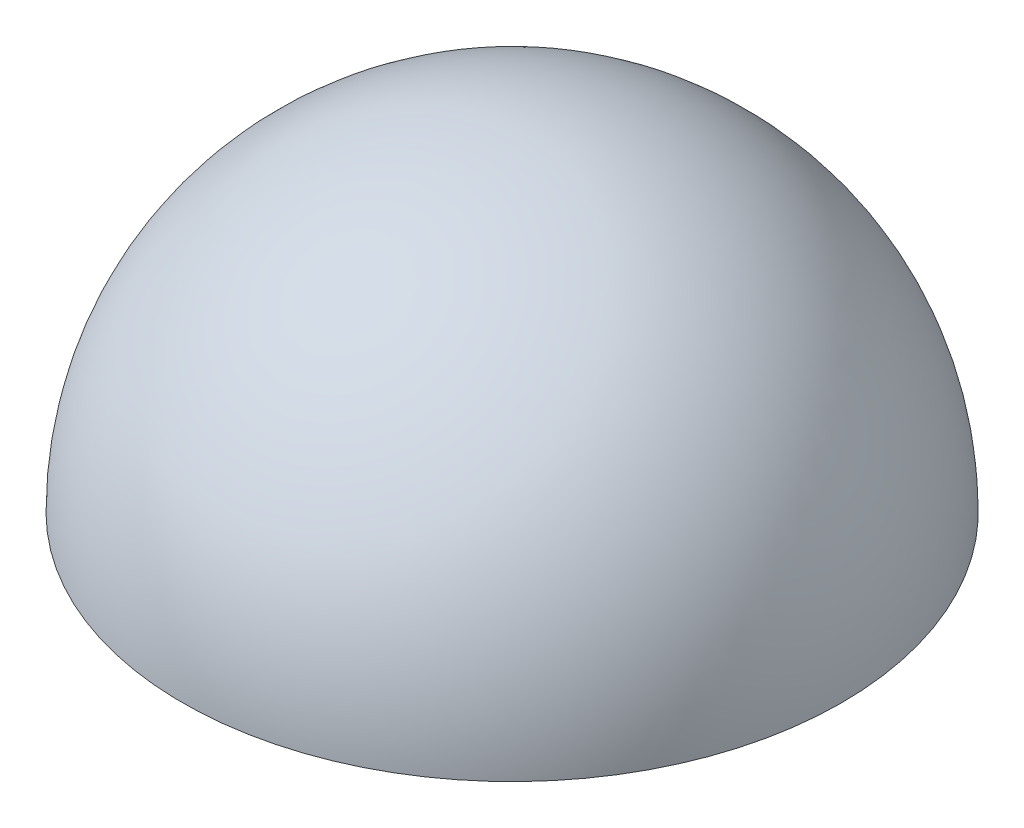
from build123d import *

# Parameters (mm, degrees)
REVOLVE1_ANGLE = 180


with BuildPart() as part:
    # Sketch1 → Revolve1 (revolve)
    with BuildSketch(Plane(origin=(0, 0, 0), x_dir=(1, 0, 0), z_dir=(0, 1, 0))):
        with BuildLine():
            ThreePointArc((4.558136028, 8.928078359), (-3.059473533, 24.015569307), (-19.722651504, 26.843794624))
            Line((-19.722651504, 26.843794624), (-8.66107644, -8.987637905))
            ThreePointArc((-8.66107644, -8.987637905), (0.895626976, -2.20431208), (4.558136028, 8.928078359))
        make_face()
    revolve(axis=Axis((-19.722651504, 0, -26.843794624), (0.294975335, 0, 0.955504867)), revolution_arc=REVOLVE1_ANGLE)


solid = part.part
